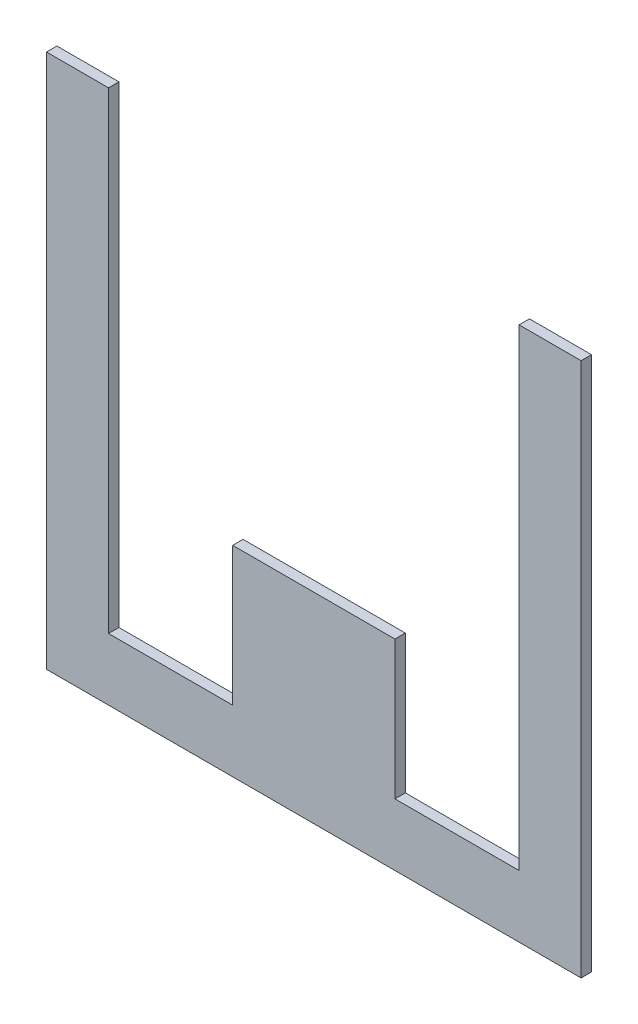
from build123d import *

# Parameters (mm, degrees)
EXTRUDE1_DEPTH = 1.7272


with BuildPart() as part:
    # Sketch1 → Extrude1 (new body)
    with BuildSketch(Plane.XY):
        Polygon((-44.45, -44.45), (44.45, -44.45), (44.45, 44.45), (34.13125, 44.45), (34.13125, -34.12998), (13.49375, -34.12998), (13.49375, -11.1125), (-13.49375, -11.1125), (-13.49375, -34.12998), (-34.13125, -34.12998), (-34.13125, 44.45), (-44.45, 44.45), align=None)
    extrude(amount=EXTRUDE1_DEPTH)


solid = part.part
